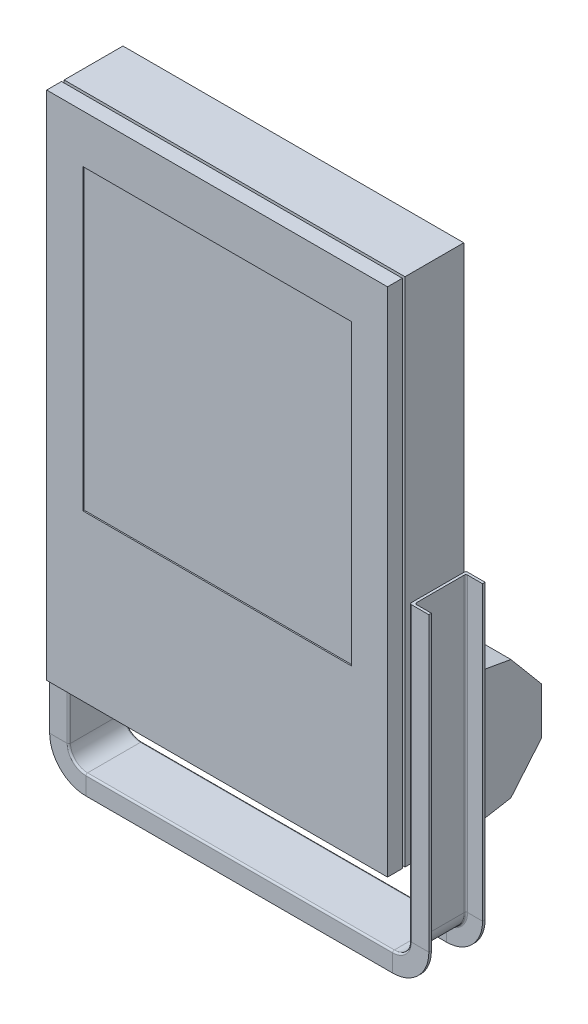
from build123d import *

# Parameters (mm, degrees)
SKETCH1_W           = 400
SKETCH1_H           = 600
BOSS_EXTRUDE1_DEPTH = 89.5
SKETCH2_W           = 315
SKETCH2_H           = 350
CUT_EXTRUDE1_DEPTH  = 1.5
SKETCH3_W           = 18.5
SKETCH3_H           = 3.1
CUT_EXTRUDE2_DEPTH  = 600
SKETCH5_W           = 3.1
SKETCH5_H           = 18.5
CUT_EXTRUDE3_DEPTH  = 363
BOSS_EXTRUDE2_DEPTH = 400


with BuildPart() as part:
    # Sketch1 → Boss-Extrude1 (new body)
    with BuildSketch(Plane.XY):
        Rectangle(SKETCH1_W, SKETCH1_H)
    extrude(amount=BOSS_EXTRUDE1_DEPTH)

    # Sketch2 → Cut-Extrude1 (cut)
    with BuildSketch(Plane.XY.offset(89.5)):
        with Locations((0, 68.5)):
            Rectangle(SKETCH2_W, SKETCH2_H)
    extrude(amount=-CUT_EXTRUDE1_DEPTH, mode=Mode.SUBTRACT)

    # Sketch3 → Cut-Extrude2 (cut)
    with BuildSketch(Plane.XZ.offset(300)):
        with Locations((-190.75, 70.55)):
            Rectangle(SKETCH3_W, SKETCH3_H)
    cut_extrude2 = extrude(amount=-CUT_EXTRUDE2_DEPTH, mode=Mode.SUBTRACT)

    # Mirror1: Cut-Extrude2 across plane
    add(cut_extrude2.mirror(Plane(origin=(0, 0, 0), x_dir=(0, 0, 1), z_dir=(1, 0, 0))), mode=Mode.SUBTRACT)

    # Sketch5 → Cut-Extrude3 (cut)
    with BuildSketch(Plane(origin=(181.5, 0, 0), x_dir=(0, 0, -1), z_dir=(1, 0, 0))):
        with Locations((-70.55, -290.75)):
            Rectangle(SKETCH5_W, SKETCH5_H)
    cut_extrude3 = extrude(amount=-CUT_EXTRUDE3_DEPTH, mode=Mode.SUBTRACT)

    # Mirror2: Cut-Extrude3 across plane
    add(cut_extrude3.mirror(Plane.ZX), mode=Mode.SUBTRACT)

    # Sketch12 → Boss-Extrude2 (add)
    with BuildSketch(Plane.ZY.offset(200)):
        Polygon((-55.28029253, -151.145910296), (-91, -193.715), (-91, -249.285), (-55.28029253, -291.854089704), (-9.082539564, -300), (0, -300), (0, -141.398503221), align=None)
    extrude(amount=-BOSS_EXTRUDE2_DEPTH)

    # Sweep1: sweep along a path in Sketch11
    with BuildLine(Plane.XY) as sweep1_path:
        Line((-200, -35), (-200, -378))
        ThreePointArc((-200, -378), (-194.142135624, -392.142135624), (-180, -398))
        Line((-180, -398), (180, -398))
        ThreePointArc((180, -398), (194.142135624, -392.142135624), (200, -378))
        Line((200, -378), (200, -35))
    # Sketch10 → Sweep1 (sweep)
    with BuildSketch(Plane(origin=(0, -35, 0), x_dir=(1, 0, 0), z_dir=(0, 1, 0))):
        with BuildLine():
            Line((-200, 0.5), (-200, -61.5))
            ThreePointArc((-200, -61.5), (-200.585786438, -62.914213562), (-202, -63.5))
            Line((-202, -63.5), (-222.5, -63.5))
            Line((-222.5, -63.5), (-222.5, -60.5))
            Line((-222.5, -60.5), (-205, -60.5))
            ThreePointArc((-205, -60.5), (-203.585786438, -59.914213562), (-203, -58.5))
            Line((-203, -58.5), (-203, -2.5))
            ThreePointArc((-203, -2.5), (-203.585786438, -1.085786438), (-205, -0.5))
            Line((-205, -0.5), (-222.5, -0.5))
            Line((-222.5, -0.5), (-222.5, 2.5))
            Line((-222.5, 2.5), (-202, 2.5))
            ThreePointArc((-202, 2.5), (-200.585786438, 1.914213562), (-200, 0.5))
        make_face()
    sweep(path=sweep1_path.line)


solid = part.part
